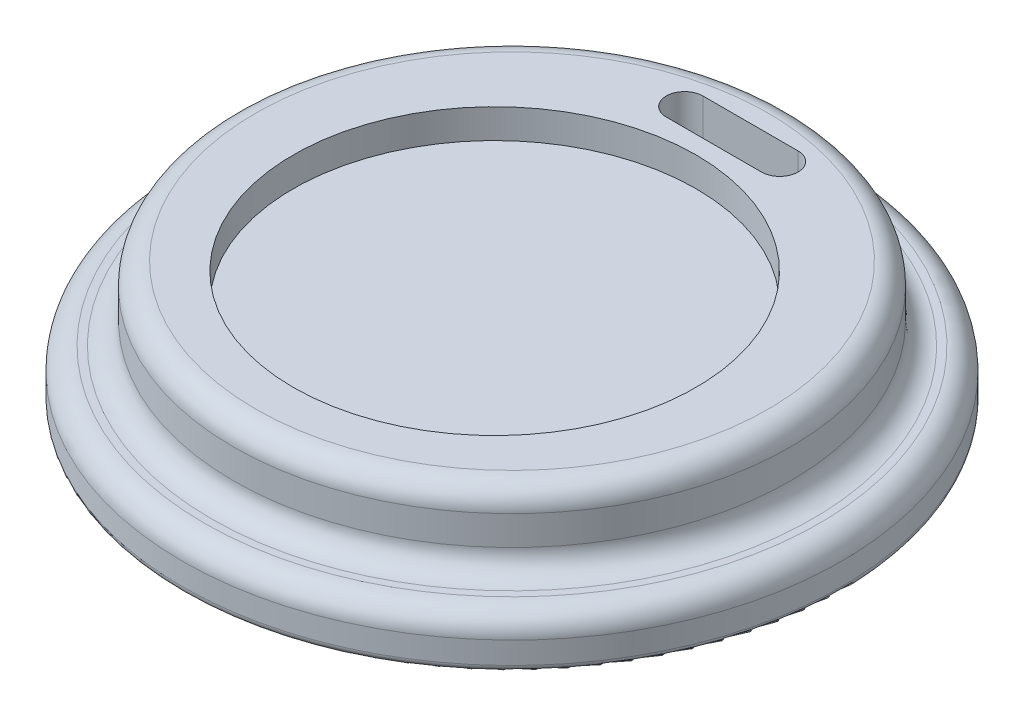
from build123d import *

# Parameters (mm, degrees)
SKETCH2_R          = 27.5
CUT_EXTRUDE1_DEPTH = 4
CUT_EXTRUDE2_DEPTH = 28


with BuildPart() as part:
    # Sketch1 → Revolve1 (revolve)
    with BuildSketch(Plane(origin=(0, 0, 0), x_dir=(0, 0, -1), z_dir=(1, 0, 0))):
        with BuildLine():
            Line((0, 0), (43, 0))
            Line((43, 0), (43, -5))
            Line((43, -5), (44, -5))
            ThreePointArc((44, -5), (44.707106781, -4.707106781), (45, -4))
            Line((45, -4), (45, -1))
            ThreePointArc((45, -1), (44.121320344, 1.121320344), (42, 2))
            Line((42, 2), (41, 2))
            ThreePointArc((41, 2), (38.878679656, 2.878679656), (38, 5))
            Line((38, 5), (38, 9))
            ThreePointArc((38, 9), (37.121320344, 11.121320344), (35, 12))
            Line((35, 12), (0, 12))
            Line((0, 12), (0, 0))
        make_face()
    revolve(axis=Axis((0, 12, 0), (0, -1, 0)))

    # Sketch2 → Cut-Extrude1 (cut)
    with BuildSketch(Plane(origin=(0, 12, 0), x_dir=(1, 0, 0), z_dir=(0, 1, 0))):
        with Locations((0, -2.368290616)):
            Circle(SKETCH2_R)
    extrude(amount=-CUT_EXTRUDE1_DEPTH, mode=Mode.SUBTRACT)

    # Sketch3 → Cut-Extrude2 (cut)
    with BuildSketch(Plane(origin=(0, 12, 0), x_dir=(1, 0, 0), z_dir=(0, 1, 0))):
        with BuildLine():
            Line((-6.5, 32.565854692), (6.5, 32.565854692))
            ThreePointArc((6.5, 32.565854692), (9, 30.065854692), (6.5, 27.565854692))
            Line((6.5, 27.565854692), (-6.5, 27.565854692))
            ThreePointArc((-6.5, 27.565854692), (-9, 30.065854692), (-6.5, 32.565854692))
        make_face()
    extrude(amount=-CUT_EXTRUDE2_DEPTH, mode=Mode.SUBTRACT)


solid = part.part
